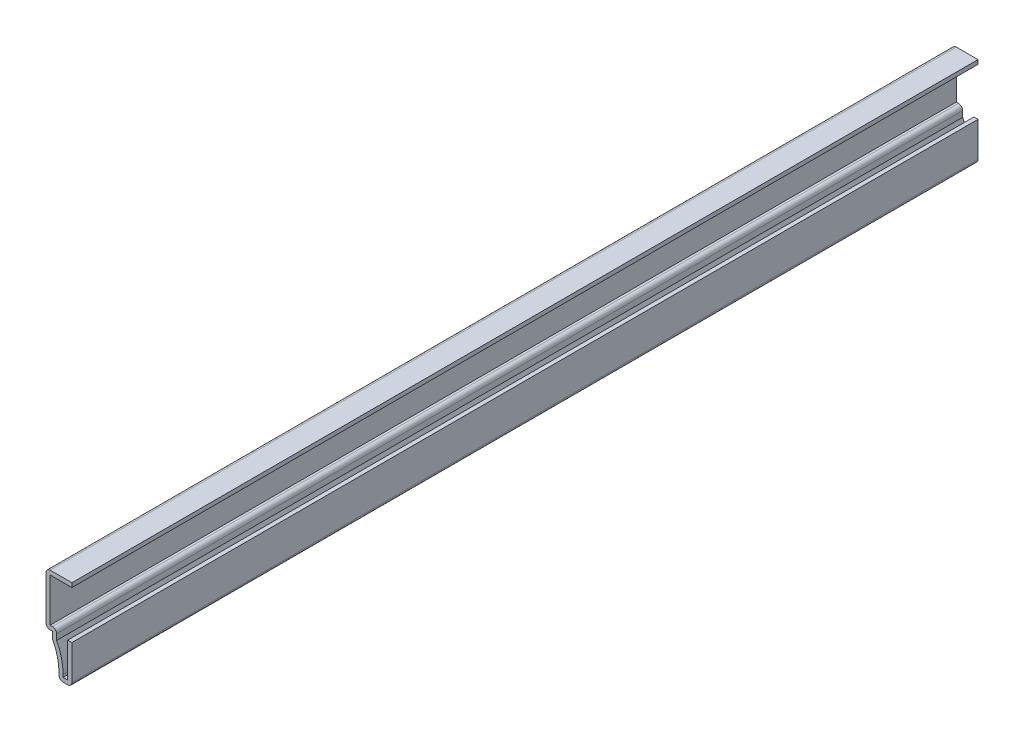
from build123d import *

# Parameters (mm, degrees)
EXTRUDE_THIN1_DEPTH = 222.25
FILLET1_R           = 1.016


with BuildPart() as part:
    # Sketch1 → Extrude-Thin1 (new body)
    with BuildSketch(Plane.XY):
        with BuildLine():
            Line((0, 0), (0, -9.525))
            Line((0, -9.525), (-3.175, -9.525))
            Line((-3.175, -9.525), (-3.175, -7.836680531))
            ThreePointArc((-3.175, -7.836680531), (-3.578277876, -4.661680531), (-4.7625, -1.688319469))
            Line((-4.7625, -1.688319469), (-4.7625, 0))
            Line((-4.7625, 0), (-6.35, 0))
            Line((-6.35, 0), (-6.35, 12.7))
            Line((-6.35, 12.7), (0, 12.7))
            Line((0, 12.7), (0, 11.684))
            Line((0, 11.684), (-5.334, 11.684))
            Line((-5.334, 11.684), (-5.334, 1.016))
            Line((-5.334, 1.016), (-3.7465, 1.016))
            Line((-3.7465, 1.016), (-3.7465, -1.431359013))
            ThreePointArc((-3.7465, -1.431359013), (-2.56178923, -4.537123743), (-2.159, -7.836680531))
            Line((-2.159, -7.836680531), (-2.159, -8.509))
            Line((-2.159, -8.509), (-1.016, -8.509))
            Line((-1.016, -8.509), (-1.016, 0))
            Line((-1.016, 0), (0, 0))
        make_face()
    extrude(amount=-EXTRUDE_THIN1_DEPTH)

    # Fillet1
    fillet1_edges = [part.edges().sort_by_distance(p)[0] for p in [
        (-3.7465, 1.016, -111.125),
        (0, -9.525, -111.125),
        (-3.175, -9.525, -111.125),
        (-4.7625, -1.688319469, -111.125),
        (-6.35, 0, -111.125),
        (-6.35, 12.7, -111.125),
    ]]
    fillet(fillet1_edges, radius=FILLET1_R)


solid = part.part
